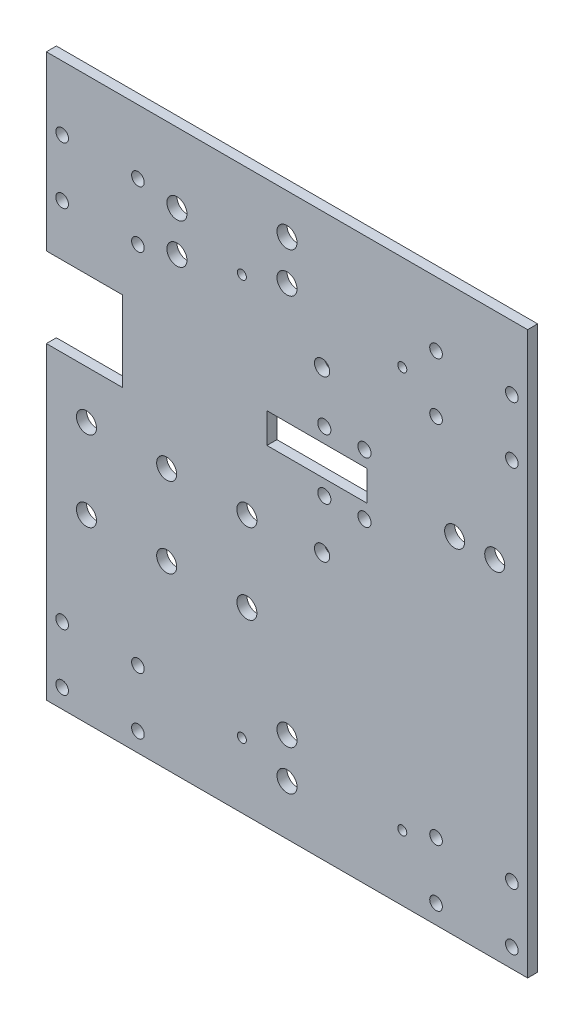
from build123d import *

# Parameters (mm, degrees)
SKETCH1_R           = 3.175
SKETCH1_R_2         = 2.0828
SKETCH1_R_3         = 2
SKETCH1_R_4         = 2.413
SKETCH1_R_5         = 1.4224
SKETCH1_W           = 31.75
SKETCH1_H           = 9.525
BOSS_EXTRUDE1_DEPTH = 3.175


with BuildPart() as part:
    # Sketch1 → Boss-Extrude1 (new body)
    with BuildSketch(Plane.XY):
        Polygon((0, 0), (152.4, 0), (152.4, 177.8), (0, 177.8), (0, 123.19), (24.171108631, 123.19), (24.171108631, 97.79), (0, 97.79), align=None)
        with Locations((38.1, 82.55)):
            Circle(SKETCH1_R, mode=Mode.SUBTRACT)
        with Locations((63.5, 82.55)):
            Circle(SKETCH1_R, mode=Mode.SUBTRACT)
        with Locations((38.1, 57.15)):
            Circle(SKETCH1_R, mode=Mode.SUBTRACT)
        with Locations((63.5, 57.15)):
            Circle(SKETCH1_R, mode=Mode.SUBTRACT)
        with Locations((88.0237, 100.0125)):
            Circle(SKETCH1_R_2, mode=Mode.SUBTRACT)
        with Locations((100.7237, 100.0125)):
            Circle(SKETCH1_R_2, mode=Mode.SUBTRACT)
        with Locations((88.0237, 119.0625)):
            Circle(SKETCH1_R_2, mode=Mode.SUBTRACT)
        with Locations((100.7237, 119.0625)):
            Circle(SKETCH1_R_2, mode=Mode.SUBTRACT)
        with Locations((129.286, 109.5375)):
            Circle(SKETCH1_R, mode=Mode.SUBTRACT)
        with Locations((123.4, 139.48)):
            Circle(SKETCH1_R_3, mode=Mode.SUBTRACT)
        with Locations((147.4, 139.48)):
            Circle(SKETCH1_R_3, mode=Mode.SUBTRACT)
        with Locations((123.4, 157.48)):
            Circle(SKETCH1_R_3, mode=Mode.SUBTRACT)
        with Locations((147.4, 157.48)):
            Circle(SKETCH1_R_3, mode=Mode.SUBTRACT)
        with Locations((5, 6)):
            Circle(SKETCH1_R_3, mode=Mode.SUBTRACT)
        with Locations((29, 6)):
            Circle(SKETCH1_R_3, mode=Mode.SUBTRACT)
        with Locations((5, 24)):
            Circle(SKETCH1_R_3, mode=Mode.SUBTRACT)
        with Locations((29, 24)):
            Circle(SKETCH1_R_3, mode=Mode.SUBTRACT)
        with Locations((5, 139.48)):
            Circle(SKETCH1_R_3, mode=Mode.SUBTRACT)
        with Locations((29, 139.48)):
            Circle(SKETCH1_R_3, mode=Mode.SUBTRACT)
        with Locations((5, 157.48)):
            Circle(SKETCH1_R_3, mode=Mode.SUBTRACT)
        with Locations((29, 157.48)):
            Circle(SKETCH1_R_3, mode=Mode.SUBTRACT)
        with Locations((123.4, 6)):
            Circle(SKETCH1_R_3, mode=Mode.SUBTRACT)
        with Locations((147.4, 6)):
            Circle(SKETCH1_R_3, mode=Mode.SUBTRACT)
        with Locations((123.4, 24)):
            Circle(SKETCH1_R_3, mode=Mode.SUBTRACT)
        with Locations((147.4, 24)):
            Circle(SKETCH1_R_3, mode=Mode.SUBTRACT)
        with Locations((41.35, 155.575)):
            Circle(SKETCH1_R, mode=Mode.SUBTRACT)
        with Locations((41.35, 142.875)):
            Circle(SKETCH1_R, mode=Mode.SUBTRACT)
        with Locations((12.7, 57.15)):
            Circle(SKETCH1_R, mode=Mode.SUBTRACT)
        with Locations((12.7, 82.55)):
            Circle(SKETCH1_R, mode=Mode.SUBTRACT)
        with Locations((141.986, 109.5375)):
            Circle(SKETCH1_R, mode=Mode.SUBTRACT)
        with Locations((87.3125, 84.1375)):
            Circle(SKETCH1_R_4, mode=Mode.SUBTRACT)
        with Locations((87.3125, 134.9375)):
            Circle(SKETCH1_R_4, mode=Mode.SUBTRACT)
        with Locations((61.9125, 147.6375)):
            Circle(SKETCH1_R_5, mode=Mode.SUBTRACT)
        with Locations((112.7125, 147.6375)):
            Circle(SKETCH1_R_5, mode=Mode.SUBTRACT)
        with Locations((112.7125, 20.6375)):
            Circle(SKETCH1_R_5, mode=Mode.SUBTRACT)
        with Locations((61.9125, 20.6375)):
            Circle(SKETCH1_R_5, mode=Mode.SUBTRACT)
        with Locations((76.2, 28.575)):
            Circle(SKETCH1_R, mode=Mode.SUBTRACT)
        with Locations((76.2, 15.875)):
            Circle(SKETCH1_R, mode=Mode.SUBTRACT)
        with Locations((76.2, 165.1)):
            Circle(SKETCH1_R, mode=Mode.SUBTRACT)
        with Locations((76.2, 152.4)):
            Circle(SKETCH1_R, mode=Mode.SUBTRACT)
        with Locations((85.725, 109.5375)):
            Rectangle(SKETCH1_W, SKETCH1_H, mode=Mode.SUBTRACT)
    extrude(amount=BOSS_EXTRUDE1_DEPTH)


solid = part.part
